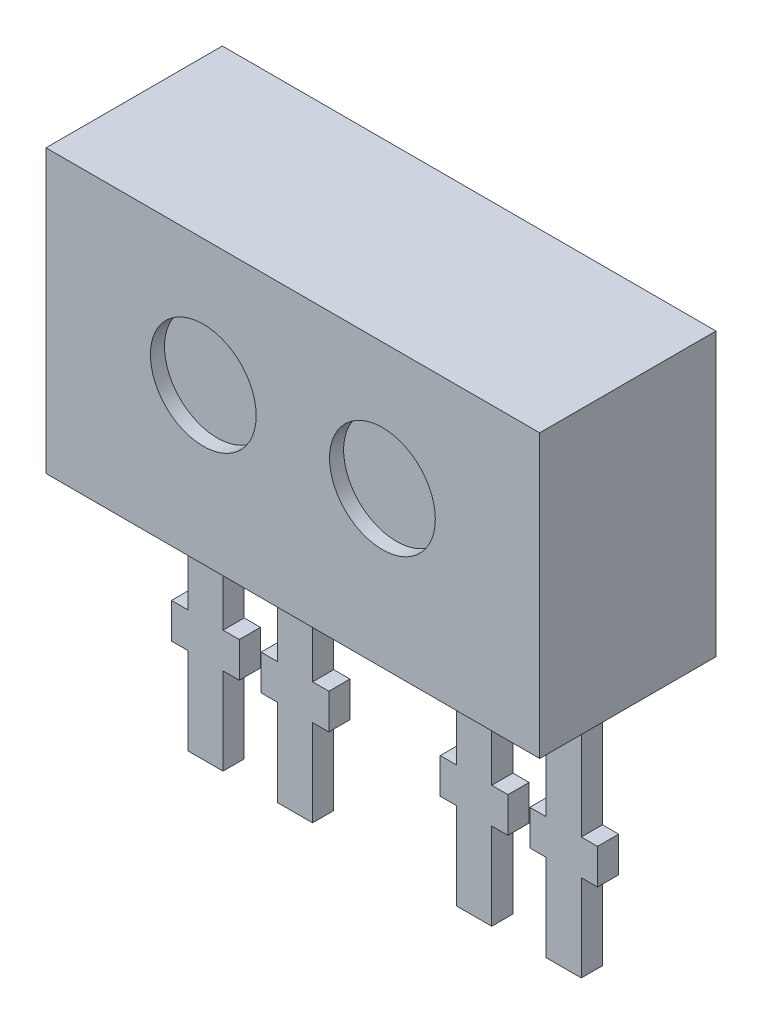
from build123d import *

# Parameters (mm, degrees)
SKETCH1_W                = 7
SKETCH1_H                = 4
BOSS_EXTRUDE1_DEPTH      = 2.5
SKETCH2_R                = 0.75
CUT_EXTRUDE1_DEPTH       = 0.2
SKETCH3_W                = 0.3
SKETCH3_H                = 3.7
BOSS_EXTRUDE2_DEPTH      = 3.5
BOSS_EXTRUDE2_DEPTH_BACK = 3.5
CUT_EXTRUDE2_DEPTH       = 3.5
CUT_EXTRUDE2_DEPTH_BACK  = 1


with BuildPart() as part:
    # Sketch1 → Boss-Extrude1 (new body)
    with BuildSketch(Plane.XY):
        Rectangle(SKETCH1_W, SKETCH1_H)
    extrude(amount=BOSS_EXTRUDE1_DEPTH)

    # Sketch2 → Cut-Extrude1 (cut)
    with BuildSketch(Plane.XY.offset(2.5)):
        with Locations((-1.27, 0.2)):
            Circle(SKETCH2_R)
        with Locations((1.27, 0.2)):
            Circle(SKETCH2_R)
    extrude(amount=-CUT_EXTRUDE1_DEPTH, mode=Mode.SUBTRACT)

    # Sketch3 → Boss-Extrude2 (add, two sides)
    with BuildSketch(Plane(origin=(0, 0, 0), x_dir=(0, 0, -1), z_dir=(1, 0, 0))) as boss_extrude2_sk:
        with Locations((-1.05, -3.85)):
            Rectangle(SKETCH3_W, SKETCH3_H)
    extrude(amount=BOSS_EXTRUDE2_DEPTH)
    extrude(boss_extrude2_sk.sketch, amount=-BOSS_EXTRUDE2_DEPTH_BACK)

    # Sketch4 → Cut-Extrude2 (cut, two sides)
    with BuildSketch(Plane.XY) as cut_extrude2_sk:
        Polygon((-2.79, -6.068420348), (-2.79, -4.468420348), (-3.020094846, -4.468420348), (-3.020094846, -3.968420348), (-2.79, -3.968420348), (-2.79, -2), (-4.136093054, -2), (-4.136093054, -6.068420348), align=None)
        Polygon((-2.29, -6.068420348), (-2.29, -4.468420348), (-2.059905154, -4.468420348), (-2.059905154, -3.968420348), (-2.29, -3.968420348), (-2.29, -2), (-1.52, -2), (-1.52, -3.968420348), (-1.750094846, -3.968420348), (-1.750094846, -4.468420348), (-1.52, -4.468420348), (-1.52, -6.068420348), align=None)
        Polygon((-1.02, -2), (1.02, -2), (1.02, -3.968420348), (0.789905154, -3.968420348), (0.789905154, -4.468420348), (1.02, -4.468420348), (1.02, -6.068420348), (-1.02, -6.068420348), (-1.02, -4.468420348), (-0.789905154, -4.468420348), (-0.789905154, -3.968420348), (-1.02, -3.968420348), align=None)
        Polygon((4.136093054, -6.068420348), (2.79, -6.068420348), (2.79, -4.468420348), (3.020094846, -4.468420348), (3.020094846, -3.968420348), (2.79, -3.968420348), (2.79, -2), (4.136093054, -2), align=None)
        Polygon((1.52, -6.068420348), (1.52, -4.468420348), (1.750094846, -4.468420348), (1.750094846, -3.968420348), (1.52, -3.968420348), (1.52, -2), (2.29, -2), (2.29, -3.968420348), (2.059905154, -3.968420348), (2.059905154, -4.468420348), (2.29, -4.468420348), (2.29, -6.068420348), align=None)
    extrude(amount=CUT_EXTRUDE2_DEPTH, mode=Mode.SUBTRACT)
    extrude(cut_extrude2_sk.sketch, amount=-CUT_EXTRUDE2_DEPTH_BACK, mode=Mode.SUBTRACT)


solid = part.part
